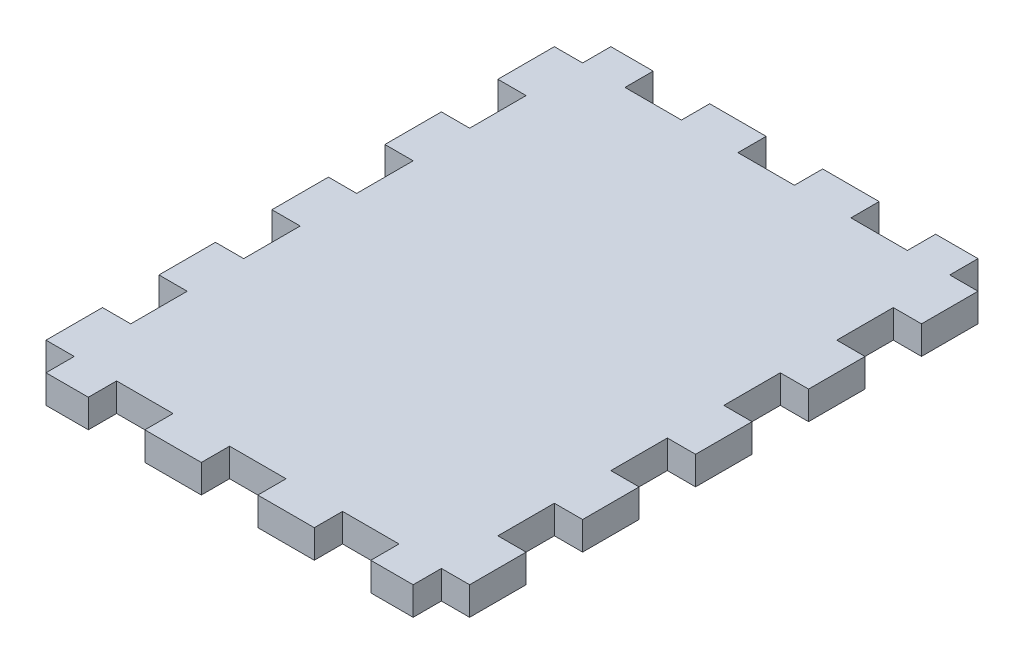
from build123d import *

# Parameters (mm, degrees)
SKETCH1_W           = 95.25
SKETCH1_H           = 127
BOSS_EXTRUDE1_DEPTH = 6.35
SKETCH2_W           = 6.35
SKETCH2_H           = 12.7
SKETCH2_H_2         = 6.35
CUT_EXTRUDE1_DEPTH  = 7.35
LPATTERN1_COUNT     = 5
LPATTERN1_PITCH     = 25.4
SKETCH4_W           = 12.7
SKETCH4_H           = 6.35
CUT_EXTRUDE3_DEPTH  = 7.35
LPATTERN2_COUNT     = 2
LPATTERN2_PITCH     = 25.4
LPATTERN2_COL_COUNT = 2
LPATTERN2_COL_PITCH = 25.4


with BuildPart() as part:
    # Sketch1 → Boss-Extrude1 (new body)
    with BuildSketch(Plane(origin=(0, 0, 0), x_dir=(1, 0, 0), z_dir=(0, 1, 0))):
        with Locations((47.625, 63.5)):
            Rectangle(SKETCH1_W, SKETCH1_H)
    extrude(amount=BOSS_EXTRUDE1_DEPTH)

    # Sketch2 → Cut-Extrude1 (cut, through all)
    with BuildSketch(Plane(origin=(0, 6.35, 0), x_dir=(1, 0, 0), z_dir=(0, 1, 0))):
        with Locations((3.175, 127)):
            Rectangle(SKETCH2_W, SKETCH2_H)
        with Locations((92.075, 127)):
            Rectangle(SKETCH2_W, SKETCH2_H)
        with Locations((3.175, 3.175)):
            Rectangle(SKETCH2_W, SKETCH2_H_2)
        with Locations((92.075, 3.175)):
            Rectangle(SKETCH2_W, SKETCH2_H_2)
    cut_extrude1 = extrude(amount=-CUT_EXTRUDE1_DEPTH, mode=Mode.SUBTRACT)

    # LPattern1: Cut-Extrude1 ×5
    with Locations(*[(0, 0, i * LPATTERN1_PITCH) for i in range(1, LPATTERN1_COUNT)]):
        add(cut_extrude1, mode=Mode.SUBTRACT)

    # Sketch4 → Cut-Extrude3 (cut, through all)
    with BuildSketch(Plane(origin=(0, 6.35, 0), x_dir=(1, 0, 0), z_dir=(0, 1, 0))):
        with Locations((47.625, 123.825)):
            Rectangle(SKETCH4_W, SKETCH4_H)
        with Locations((47.625, 3.175)):
            Rectangle(SKETCH4_W, SKETCH4_H)
    cut_extrude3 = extrude(amount=-CUT_EXTRUDE3_DEPTH, mode=Mode.SUBTRACT)

    # LPattern2: Cut-Extrude3 ×2
    with Locations(*[(-i * LPATTERN2_PITCH, 0, 0) for i in range(1, LPATTERN2_COUNT)]):
        add(cut_extrude3, mode=Mode.SUBTRACT)

    # LPattern2 col: Cut-Extrude3 ×2
    with Locations(*[(i * LPATTERN2_COL_PITCH, 0, 0) for i in range(1, LPATTERN2_COL_COUNT)]):
        add(cut_extrude3, mode=Mode.SUBTRACT)


solid = part.part
